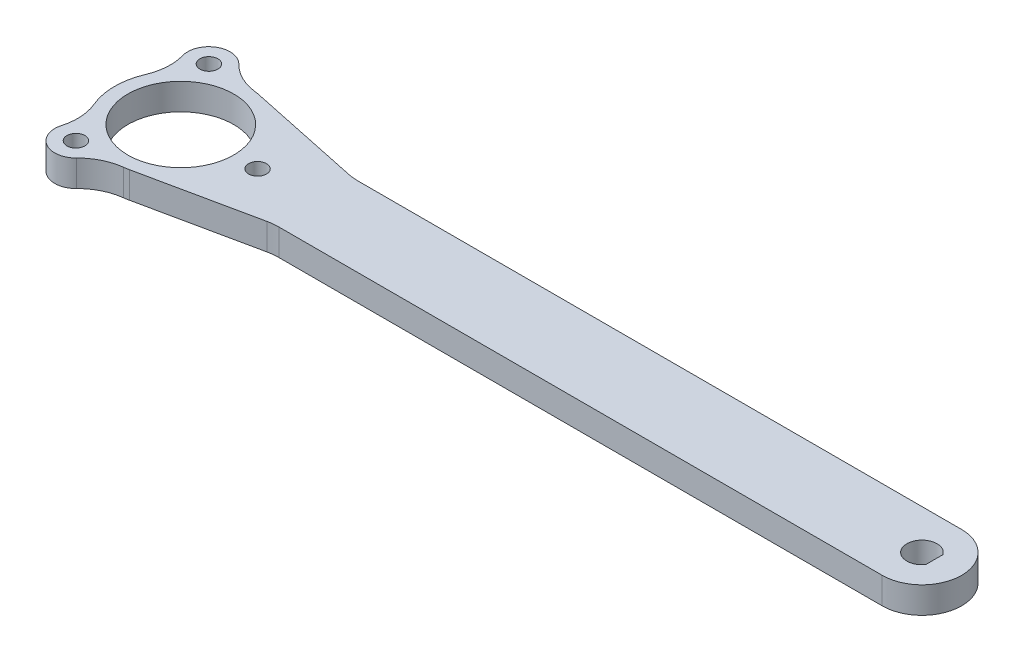
from build123d import *

# Parameters (mm, degrees)
SKETCH1_R            = 10
BOSS_EXTRUDE1_DEPTH  = 5
BOSS_EXTRUDE3_DEPTH  = 5
M3_CLEARANCE_HOLE1_D = 3.4
CIRPATTERN1_COUNT    = 3
FILLET1_R            = 10


with BuildPart() as part:
    # Sketch1 → Boss-Extrude1 (new body)
    with BuildSketch(Plane(origin=(0, 0, 0), x_dir=(1, 0, 0), z_dir=(0, 1, 0))):
        with BuildLine():
            Line((25, 7.5), (2.58079654, 12.230678199))
            ThreePointArc((2.58079654, 12.230678199), (-12.5, 0), (2.58079654, -12.230678199))
            Line((2.58079654, -12.230678199), (25, -7.5))
            Line((25, -7.5), (140, -7.5))
            ThreePointArc((140, -7.5), (147.5, 0), (140, 7.5))
            Line((140, 7.5), (25, 7.5))
        make_face()
        with Locations(Location((0, 0, 0), (0, 0, 270))):
            Circle(SKETCH1_R, mode=Mode.SUBTRACT)
        with BuildLine():
            ThreePointArc((142.348879749, -1.614082998), (137.15, 0), (142.348879749, 1.614082998))
            Line((142.348879749, 1.614082998), (142.348879749, -1.614082998))
        make_face(mode=Mode.SUBTRACT)
    extrude(amount=BOSS_EXTRUDE1_DEPTH)

    # Sketch2 → Boss-Extrude3 (add)
    with BuildSketch(Plane(origin=(0, 5, 0), x_dir=(1, 0, 0), z_dir=(0, 1, 0))):
        with BuildLine():
            ThreePointArc((-6.25, 10.825317547), (-4.412013956, 11.695474888), (-2.457258026, 12.256095748))
            Line((-2.457258026, 12.256095748), (-3.785898385, 14.557368355))
            ThreePointArc((-3.785898385, 14.557368355), (-9.25, 16.02146997), (-10.714101615, 10.557368355))
            Line((-10.714101615, 10.557368355), (-9.385461256, 8.256095748))
            ThreePointArc((-9.385461256, 8.256095748), (-7.922571384, 9.668653612), (-6.25, 10.825317547))
        make_face()
    boss_extrude3 = extrude(amount=-BOSS_EXTRUDE3_DEPTH)

    # M3 Clearance Hole1 (through all)
    with Locations(Plane(origin=(0, 5, 0), x_dir=(1, 0, 0), z_dir=(0, 1, 0))):
        with Locations((-7.25, 12.557368355)):
            m3_clearance_hole1 = Hole(M3_CLEARANCE_HOLE1_D / 2)

    # CirPattern1: Boss-Extrude3, M3 Clearance Hole1 ×3 about axis
    cirpattern1_axis = Axis((0, 0, 0), (0, 1, 0))
    add([boss_extrude3.rotate(cirpattern1_axis, i * 360 / CIRPATTERN1_COUNT) for i in range(1, CIRPATTERN1_COUNT)])
    add([m3_clearance_hole1.rotate(cirpattern1_axis, i * 360 / CIRPATTERN1_COUNT) for i in range(1, CIRPATTERN1_COUNT)], mode=Mode.SUBTRACT)

    # Fillet1
    fillet1_edges = [part.edges().sort_by_distance(p)[0] for p in [
        (-2.457258026, 2.5, 12.256095748),
        (-9.385461256, 2.5, 8.256095748),
        (-9.385461256, 2.5, -8.256095748),
        (-2.457258026, 2.5, -12.256095748),
        (25, 2.5, 7.5),
        (25, 2.5, -7.5),
    ]]
    fillet(fillet1_edges, radius=FILLET1_R)


solid = part.part
